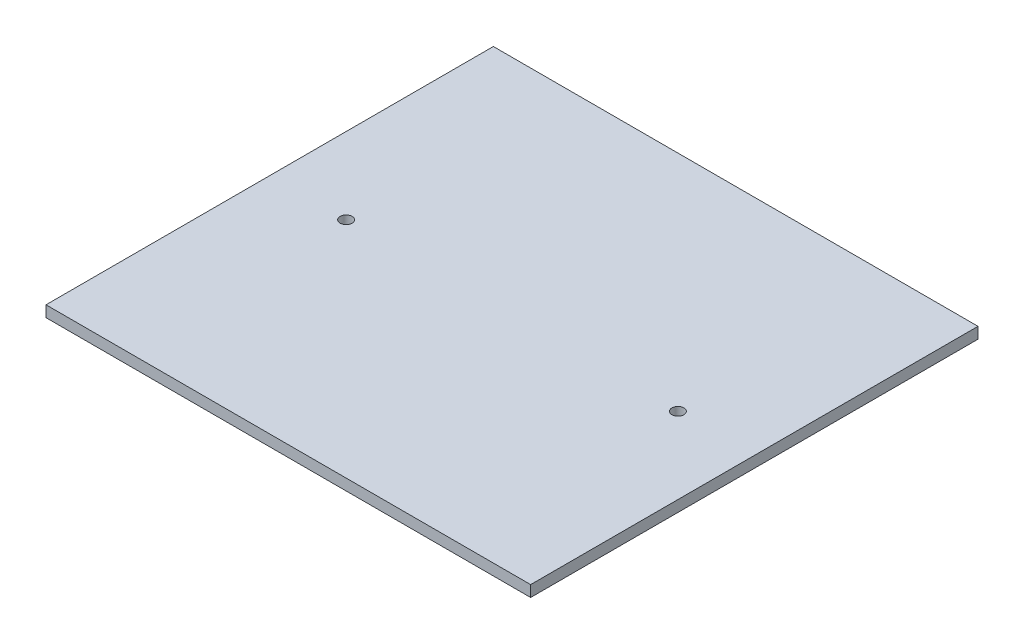
from build123d import *

# Parameters (mm, degrees)
SKETCH1_W           = 130
SKETCH1_H           = 120
BOSS_EXTRUDE1_DEPTH = 3
CUT_EXTRUDE1_START  = -4
SKETCH2_R           = 1.6
CUT_EXTRUDE1_DEPTH  = 5


with BuildPart() as part:
    # Sketch1 → Boss-Extrude1 (new body)
    with BuildSketch(Plane(origin=(0, 0, 0), x_dir=(1, 0, 0), z_dir=(0, 1, 0))):
        Rectangle(SKETCH1_W, SKETCH1_H)
    extrude(amount=BOSS_EXTRUDE1_DEPTH)

    # Sketch2 → Cut-Extrude1 (cut)
    with BuildSketch(Plane(origin=(0, 3, 0), x_dir=(1, 0, 0), z_dir=(0, 1, 0)).offset(CUT_EXTRUDE1_START)):
        with Locations((44.5, 0)):
            Circle(SKETCH2_R)
    cut_extrude1 = extrude(amount=CUT_EXTRUDE1_DEPTH, mode=Mode.SUBTRACT)

    # Mirror1: Cut-Extrude1 across plane
    add(cut_extrude1.mirror(Plane(origin=(0, 0, 0), x_dir=(0, 0, 1), z_dir=(1, 0, 0))), mode=Mode.SUBTRACT)


solid = part.part
